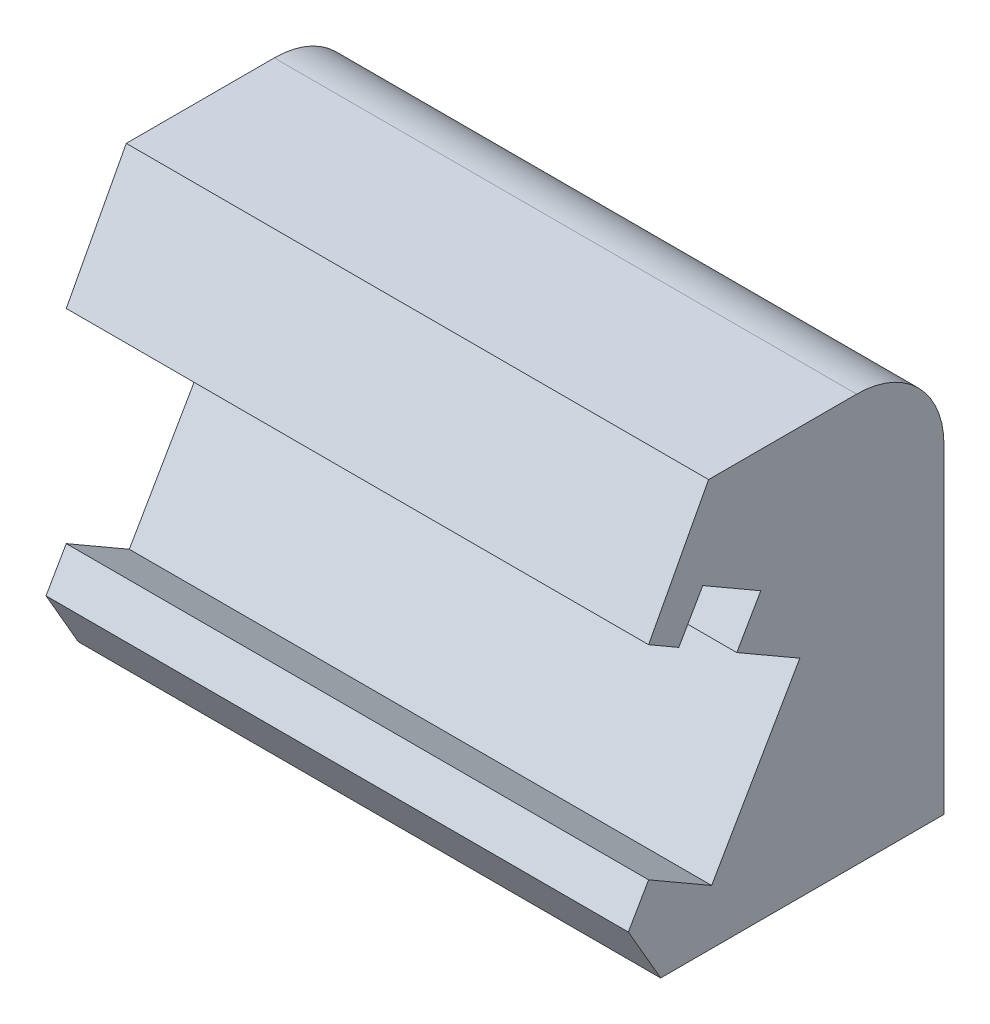
from build123d import *

# Parameters (mm, degrees)
BOSS_EXTRUDE1_DEPTH      = 10
BOSS_EXTRUDE1_DEPTH_BACK = 10
CUT_EXTRUDE1_DEPTH       = 10
CUT_EXTRUDE1_DEPTH_BACK  = 10


with BuildPart() as part:
    # Sketch13 → Boss-Extrude1 (new, two sides: drawn at the far end of the back side and taken through both)
    with BuildSketch(Plane(origin=(-31.8, 0, 0), x_dir=(0, 0, -1), z_dir=(1, 0, 0)).offset(-BOSS_EXTRUDE1_DEPTH_BACK)):
        with BuildLine():
            Line((6.746523488, 9.38), (3.731523488, 14.602133185))
            Line((3.731523488, 14.602133185), (8.392906101, 23.38137644))
            Line((8.392906101, 23.38137644), (13.476604558, 23.38137644))
            ThreePointArc((13.476604558, 23.38137644), (15.597924901, 22.502696784), (16.476604558, 20.38137644))
            Line((16.476604558, 20.38137644), (16.476604558, 9.38))
            Line((16.476604558, 9.38), (6.746523488, 9.38))
        make_face()
    extrude(amount=BOSS_EXTRUDE1_DEPTH + BOSS_EXTRUDE1_DEPTH_BACK)

    # Sketch15 → Cut-Extrude1 (cut, two sides: drawn at the far end of the back side and taken through both)
    with BuildSketch(Plane(origin=(-31.8, 0, 0), x_dir=(0, 0, -1), z_dir=(1, 0, 0)).offset(-CUT_EXTRUDE1_DEPTH_BACK)):
        Polygon((10.184407321, 19.178855838), (9.360685737, 17.752128204), (11.525749246, 16.502128204), (8.497418172, 11.256904921), (6.332354663, 12.506904921), (5.636779377, 11.302133185), (3.617891994, 14.798948707), (6.332354663, 19.500535964), (7.368827308, 18.902128204), (8.192548892, 20.328855838), align=None)
    extrude(amount=CUT_EXTRUDE1_DEPTH + CUT_EXTRUDE1_DEPTH_BACK, mode=Mode.SUBTRACT)


solid = part.part
